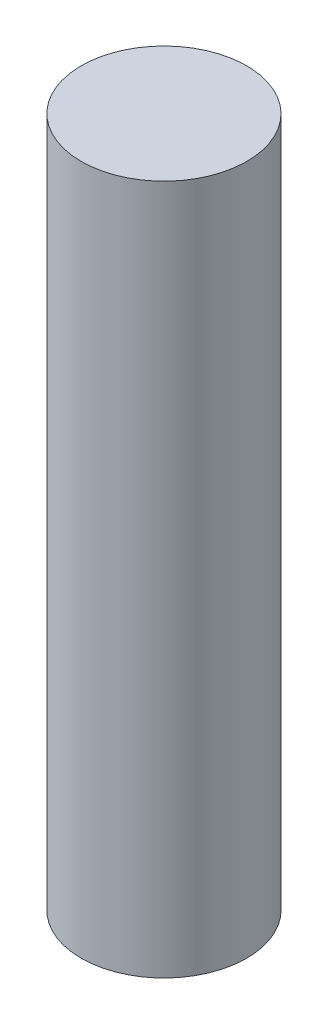
from build123d import *

# Parameters (mm, degrees)
SKETCH1_R           = 1.5
BOSS_EXTRUDE1_DEPTH = 12.5


with BuildPart() as part:
    # Sketch1 → Boss-Extrude1 (new body)
    with BuildSketch(Plane(origin=(0, 0, 0), x_dir=(1, 0, 0), z_dir=(0, 1, 0))):
        Circle(SKETCH1_R)
    extrude(amount=BOSS_EXTRUDE1_DEPTH)


solid = part.part
